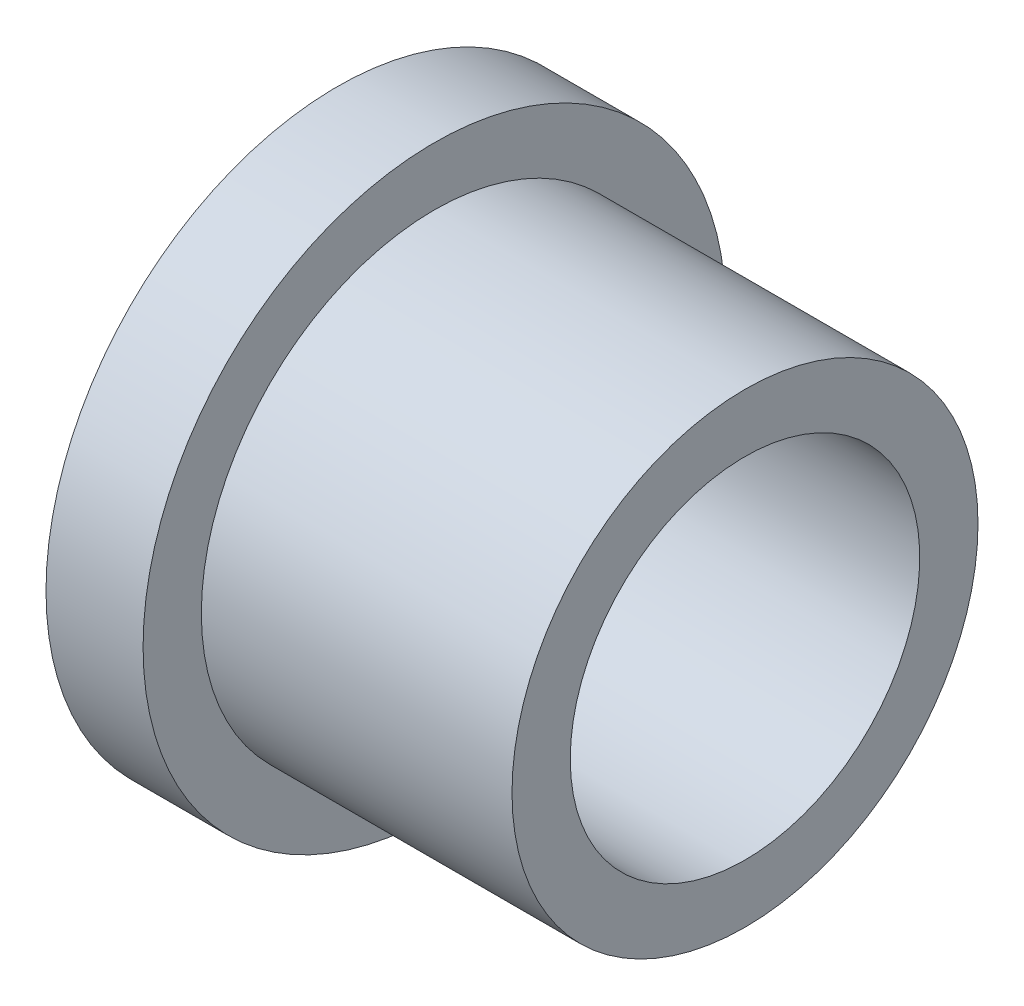
from build123d import *


with BuildPart() as part:
    # Sketch1 → Revolve1 (revolve)
    with BuildSketch(Plane.XY):
        Polygon((0, 9), (0, 15), (5, 15), (5, 12), (21, 12), (21, 9), align=None)
    revolve(axis=Axis((0, 0, 0), (1, 0, 0)))


solid = part.part
